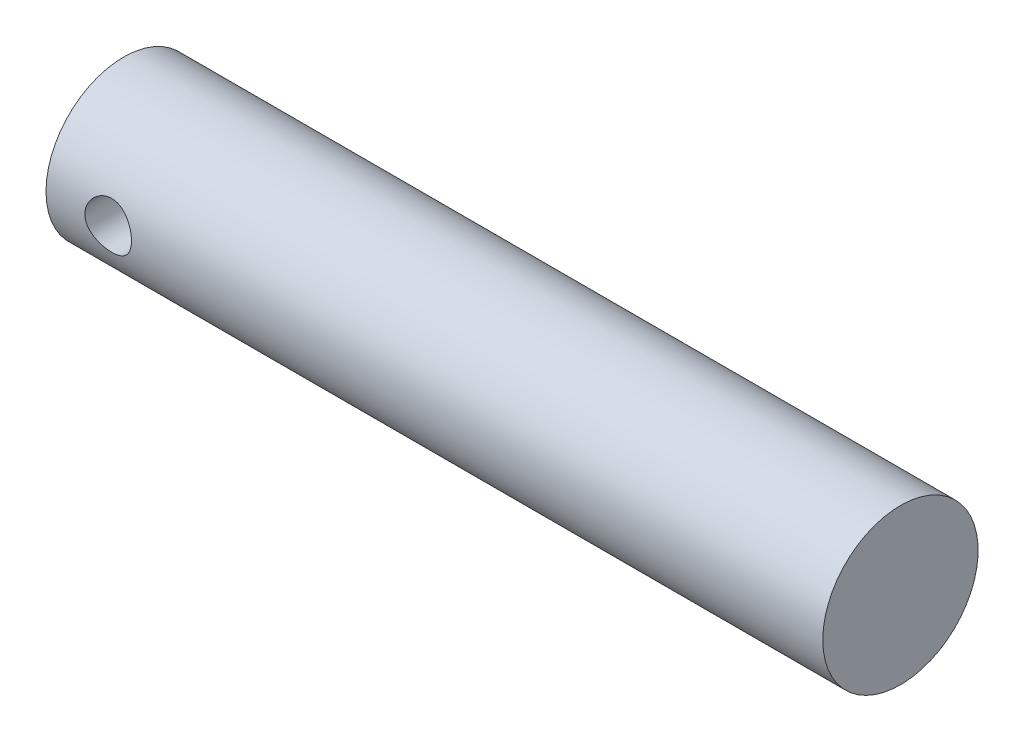
from build123d import *

# Parameters (mm, degrees)
SKIZZE1_W                                   = 100
SKIZZE1_H                                   = 10
SCHNITT_LINEAR_AUSTRAGEN1_REACH             = 12
SKIZZE2_R                                   = 3
SCHNITT_LINEAR_AUSTRAGEN1_DIRECTION_2_REACH = 12


with BuildPart() as part:
    # Skizze1 → Rotation1 (revolve)
    with BuildSketch(Plane.XY):
        with Locations((50, 5)):
            Rectangle(SKIZZE1_W, SKIZZE1_H)
    revolve(axis=Axis((0, 0, 0), (1, 0, 0)))

    # Skizze2 → Schnitt-Linear austragen1 (cut, up to next)
    with BuildSketch(Plane.XY, mode=Mode.PRIVATE) as schnitt_linear_austragen1_sk1:
        with Locations((8, 0)):
            Circle(SKIZZE2_R)
    schnitt_linear_austragen1_tool1 = extrude(schnitt_linear_austragen1_sk1.sketch, amount=-SCHNITT_LINEAR_AUSTRAGEN1_REACH, mode=Mode.PRIVATE) & part.part
    add(schnitt_linear_austragen1_tool1.solids().sort_by_distance((8, 0, 0))[0], mode=Mode.SUBTRACT)

    # Skizze2 → Schnitt-Linear austragen1 direction 2 (cut, up to next)
    with BuildSketch(Plane.XY, mode=Mode.PRIVATE) as schnitt_linear_austragen1_direction_2_sk1:
        with Locations((8, 0)):
            Circle(SKIZZE2_R)
    schnitt_linear_austragen1_direction_2_tool1 = extrude(schnitt_linear_austragen1_direction_2_sk1.sketch, amount=SCHNITT_LINEAR_AUSTRAGEN1_DIRECTION_2_REACH, mode=Mode.PRIVATE) & part.part
    add(schnitt_linear_austragen1_direction_2_tool1.solids().sort_by_distance((8, 0, 0))[0], mode=Mode.SUBTRACT)


solid = part.part
